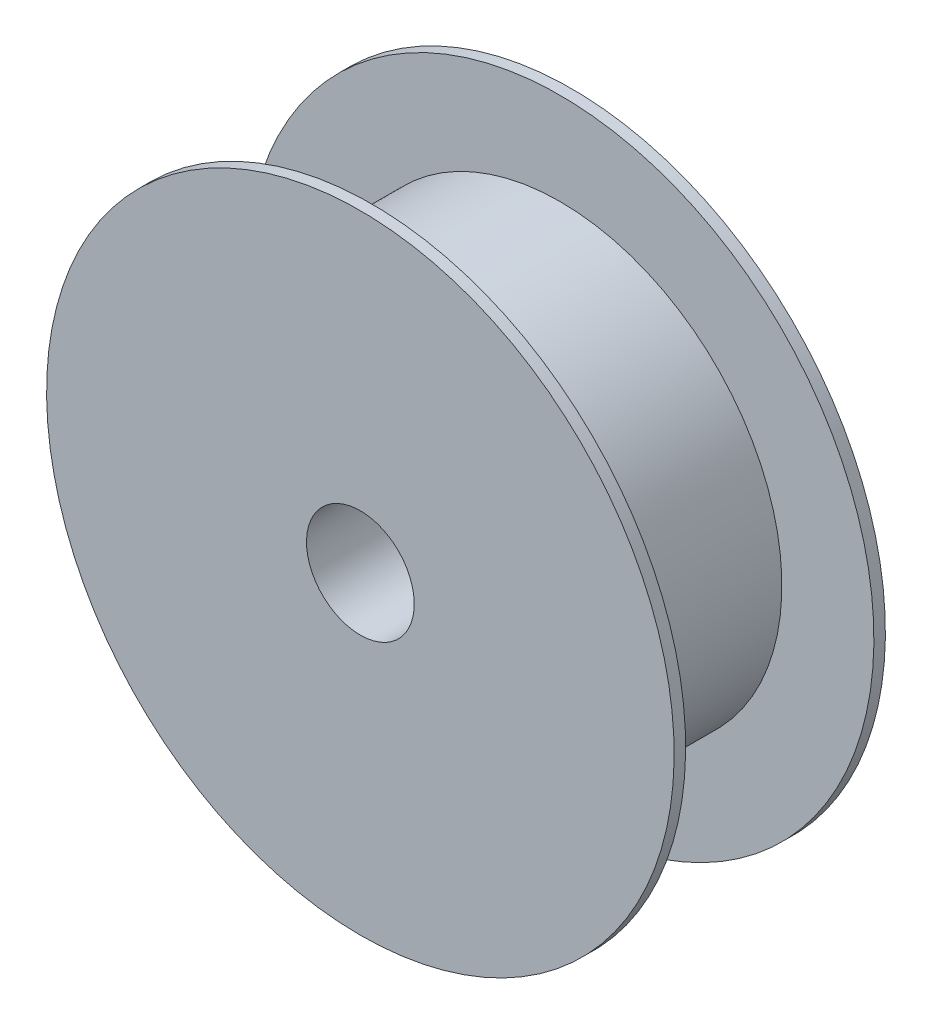
from build123d import *


with BuildPart() as part:
    # Croquis1 one side → Revolución1 (revolve)
    with BuildSketch(Plane(origin=(0, 0, 0), x_dir=(0, 0, -1), z_dir=(1, 0, 0))):
        Polygon((-45, 106), (-45, 150), (-50.5, 150), (-50.5, 25.75), (50.5, 25.75), (50.5, 150), (45, 150), (45, 106), align=None)
    revolve(axis=Axis((0, 0, 50.5), (0, 0, -1)))


solid = part.part
